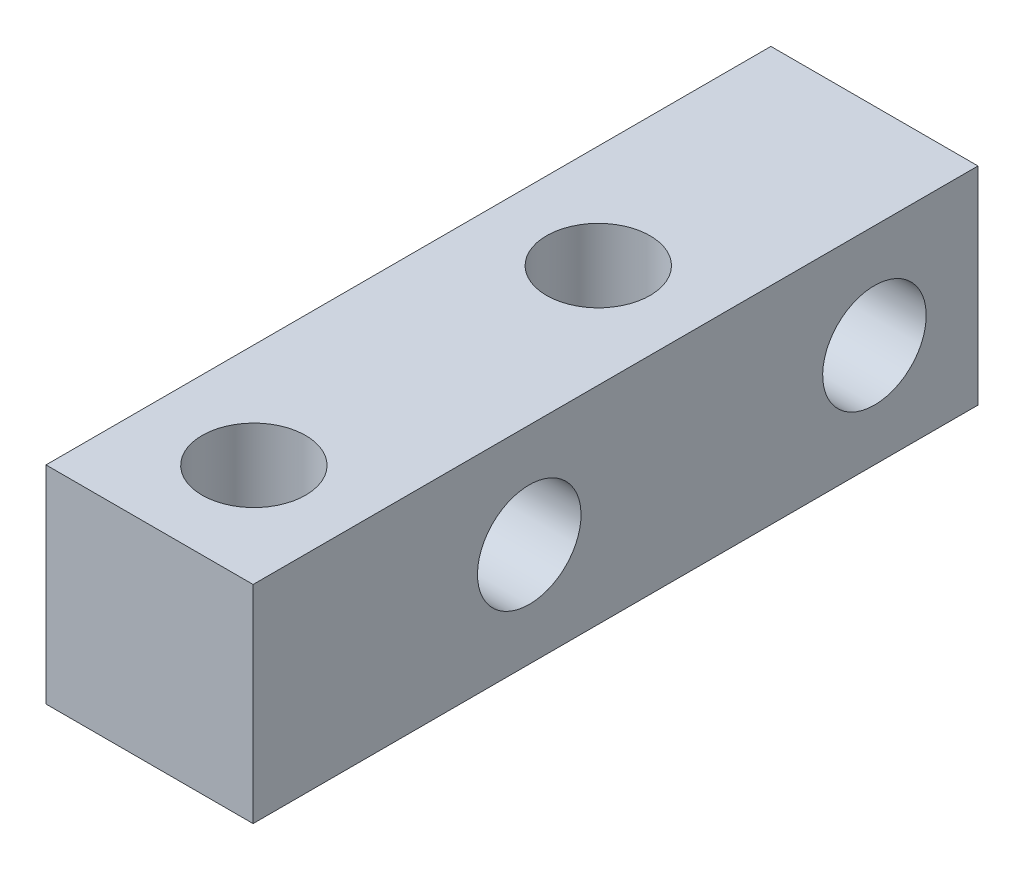
from build123d import *

# Parameters (mm, degrees)
SKETCH_1_W          = 6
SKETCH_1_H          = 6
EXTRUDE_1_DEPTH     = 21
SKETCH_2_R          = 1.5
CUT_EXTRUDE_1_DEPTH = 21
SKETCH_3_R          = 1.5
CUT_EXTRUDE_2_DEPTH = 21


with BuildPart() as part:
    # 草图1 → 凸台-拉伸1 (new body)
    with BuildSketch(Plane.XY):
        Rectangle(SKETCH_1_W, SKETCH_1_H)
    extrude(amount=EXTRUDE_1_DEPTH)

    # 草图2 → 切除-拉伸1 (cut)
    with BuildSketch(Plane.ZY.offset(3)):
        with Locations((3, 0)):
            Circle(SKETCH_2_R)
        with Locations((13, 0)):
            Circle(SKETCH_2_R)
    extrude(amount=-CUT_EXTRUDE_1_DEPTH, mode=Mode.SUBTRACT)

    # 草图3 → 切除-拉伸2 (cut)
    with BuildSketch(Plane(origin=(0, 3, 0), x_dir=(1, 0, 0), z_dir=(0, 1, 0))):
        with Locations((0.02150406, -18)):
            Circle(SKETCH_3_R)
        with Locations((0, -8)):
            Circle(SKETCH_3_R)
    extrude(amount=-CUT_EXTRUDE_2_DEPTH, mode=Mode.SUBTRACT)


solid = part.part
